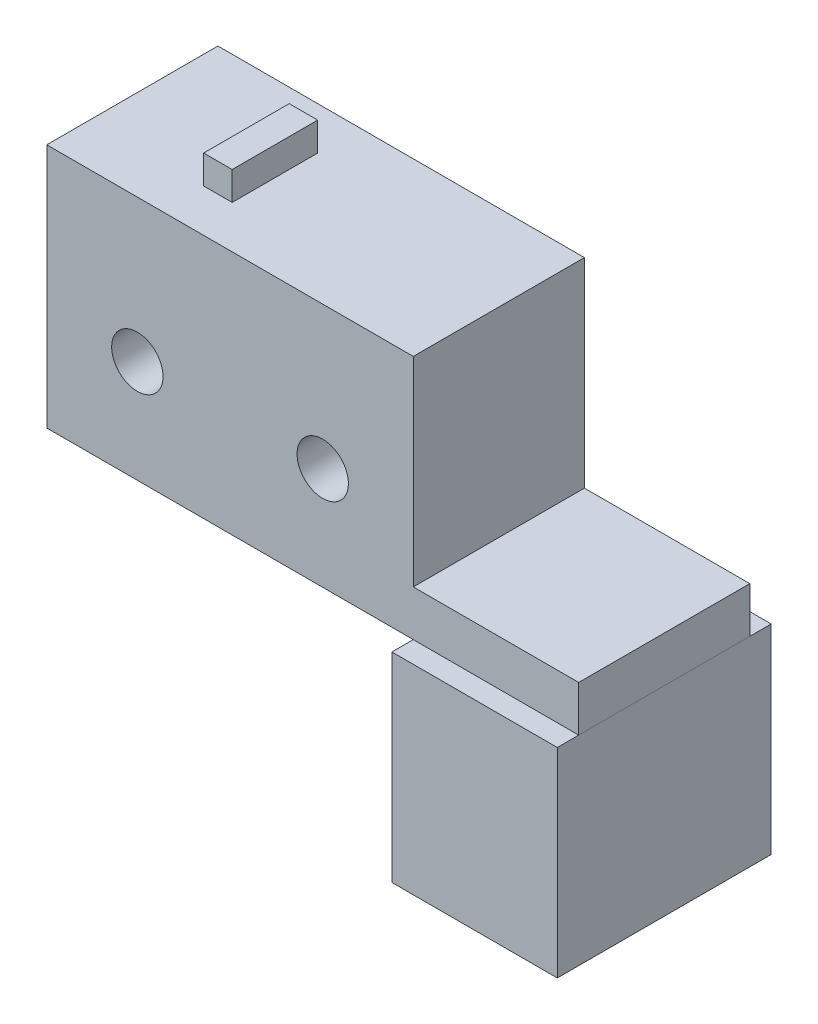
from build123d import *

# Parameters (mm, degrees)
SKETCH1_R           = 1.5
BOSS_EXTRUDE1_DEPTH = 1.6
SKETCH2_W           = 12.85
SKETCH2_H           = 10
BOSS_EXTRUDE2_DEPTH = 6
SKETCH3_W           = 12.85
SKETCH3_H           = 3
CUT_EXTRUDE1_DEPTH  = 3
CUT_EXTRUDE3_DEPTH  = 3
SKETCH5_W           = 2.25
SKETCH5_H           = 2.25
CUT_EXTRUDE4_DEPTH  = 17
BOSS_EXTRUDE4_DEPTH = 4.75
SKETCH11_W          = 12.85
SKETCH11_H          = 10
CUT_EXTRUDE8_DEPTH  = 4.75
SKETCH_1_W          = 10
SKETCH_1_H          = 7
EXTRUDE_1_DEPTH     = 5.8
CUT_EXTRUDE_1_DEPTH = 19
SKETCH_4_R          = 0.9
CUT_EXTRUDE_2_DEPTH = 7
SKETCH_5_W          = 18.65
SKETCH_5_H          = 6
EXTRUDE_3_DEPTH     = 1.6
SKETCH_6_W          = 5.8
SKETCH_6_H          = 7.5
EXTRUDE_4_DEPTH     = 7
SKETCH_2_W          = 1
SKETCH_2_H          = 3
EXTRUDE_2_DEPTH     = 1
SHELL_1_T           = -0.5


with BuildPart() as part:
    # Sketch1 → Boss-Extrude1 (new body)
    with BuildSketch(Plane.XY):
        with BuildLine():
            Line((-7, 20), (7, 20))
            ThreePointArc((7, 20), (8.414213562, 19.414213562), (9, 18))
            Line((9, 18), (9, 2))
            ThreePointArc((9, 2), (8.414213562, 0.585786438), (7, 0))
            Line((7, 0), (-7, 0))
            ThreePointArc((-7, 0), (-8.414213562, 0.585786438), (-9, 2))
            Line((-9, 2), (-9, 18))
            ThreePointArc((-9, 18), (-8.414213562, 19.414213562), (-7, 20))
        make_face()
        with Locations((7, 5)):
            Circle(SKETCH1_R, mode=Mode.SUBTRACT)
        with Locations((-7, 5)):
            Circle(SKETCH1_R, mode=Mode.SUBTRACT)
    extrude(amount=BOSS_EXTRUDE1_DEPTH)

    # Sketch2 → Boss-Extrude2 (add)
    with BuildSketch(Plane.XY.offset(1.6)):
        with Locations((0.575, 15)):
            Rectangle(SKETCH2_W, SKETCH2_H)
    extrude(amount=BOSS_EXTRUDE2_DEPTH)

    # Sketch3 → Cut-Extrude1 (cut)
    with BuildSketch(Plane.XY.offset(7.6)):
        with Locations((0.575, 11.5)):
            Rectangle(SKETCH3_W, SKETCH3_H)
    extrude(amount=-CUT_EXTRUDE1_DEPTH, mode=Mode.SUBTRACT)

    # Sketch4 → Cut-Extrude3 (cut)
    with BuildSketch(Plane.XY.offset(4.6)):
        Polygon((5, 13), (1.575, 13), (1.575, 10), (5, 10), (5, 11.5), align=None)
        Polygon((-0.425, 13), (-3.85, 13), (-3.85, 11.5), (-3.85, 10), (-0.425, 10), align=None)
    extrude(amount=-CUT_EXTRUDE3_DEPTH, mode=Mode.SUBTRACT)

    # Sketch5 → Cut-Extrude4 (cut, through all)
    with BuildSketch(Plane(origin=(7, 0, 0), x_dir=(0, 0, -1), z_dir=(1, 0, 0))):
        with Locations((-2.725, 11.875)):
            Rectangle(SKETCH5_W, SKETCH5_H)
    extrude(amount=-CUT_EXTRUDE4_DEPTH, mode=Mode.SUBTRACT)

    # Sketch10 → Boss-Extrude4 (add)
    with BuildSketch(Plane.XY.offset(7.6)):
        Polygon((6.995, 23.262214419), (-5.85, 20), (-5.45, 20), (6.995, 23.16062736), align=None)
    extrude(amount=-BOSS_EXTRUDE4_DEPTH)

    # Sketch11 → Cut-Extrude8 (cut)
    with BuildSketch(Plane(origin=(0, 20, 0), x_dir=(1, 0, 0), z_dir=(0, 1, 0))):
        with Locations((0.575, -2.6)):
            Rectangle(SKETCH11_W, SKETCH11_H)
    extrude(amount=CUT_EXTRUDE8_DEPTH, mode=Mode.SUBTRACT)

    # 草图1 → 凸台-拉伸1 (add)
    with BuildSketch(Plane.XY.offset(1.6)):
        with Locations((-1, 1.5)):
            Rectangle(SKETCH_1_W, SKETCH_1_H)
    extrude(amount=EXTRUDE_1_DEPTH)

    # 草图3 → 切除-拉伸1 (cut, through all)
    with BuildSketch(Plane.ZY.offset(9)):
        Polygon((1.6, 18), (1.6, 10.75), (10.36696293, 10.75), (10.36696293, -5.882154517), (-1.752130291, -5.882154517), (-1.752130291, 20.931214204), (1.6, 20.931214204), align=None)
    extrude(amount=-CUT_EXTRUDE_1_DEPTH, mode=Mode.SUBTRACT)

    # 草图4 → 切除-拉伸2 (cut, through all)
    with BuildSketch(Plane.XY.offset(7.6)):
        with Locations((-2.675, 15)):
            Circle(SKETCH_4_R)
        with Locations((3.825, 15)):
            Circle(SKETCH_4_R)
    extrude(amount=-CUT_EXTRUDE_2_DEPTH, mode=Mode.SUBTRACT)

    # 草图5 → 凸台-拉伸3 (add)
    with BuildSketch(Plane.XZ.offset(-13)):
        with Locations((3.475, 4.6)):
            Rectangle(SKETCH_5_W, SKETCH_5_H)
    extrude(amount=EXTRUDE_3_DEPTH)

    # 草图2 → 凸台-拉伸2 (add)
    with BuildSketch(Plane(origin=(0, 20, 0), x_dir=(1, 0, 0), z_dir=(0, 1, 0))):
        with Locations((-1.35, -4.6)):
            Rectangle(SKETCH_2_W, SKETCH_2_H)
    extrude(amount=EXTRUDE_2_DEPTH)


with BuildPart() as body_2:
    # 草图6 → 凸台-拉伸4 (new body)
    with BuildSketch(Plane.XZ.offset(-11.4)):
        with Locations((9.9, 4.6)):
            Rectangle(SKETCH_6_W, SKETCH_6_H)
    extrude(amount=EXTRUDE_4_DEPTH)

    # 抽壳1
    shell_1_openings = [body_2.faces().sort_by_distance(p)[0] for p in [
        (9.9, 4.4, 4.6),
    ]]
    offset(amount=SHELL_1_T, openings=shell_1_openings, kind=Kind.INTERSECTION)


solid = Compound([part.part, body_2.part])
